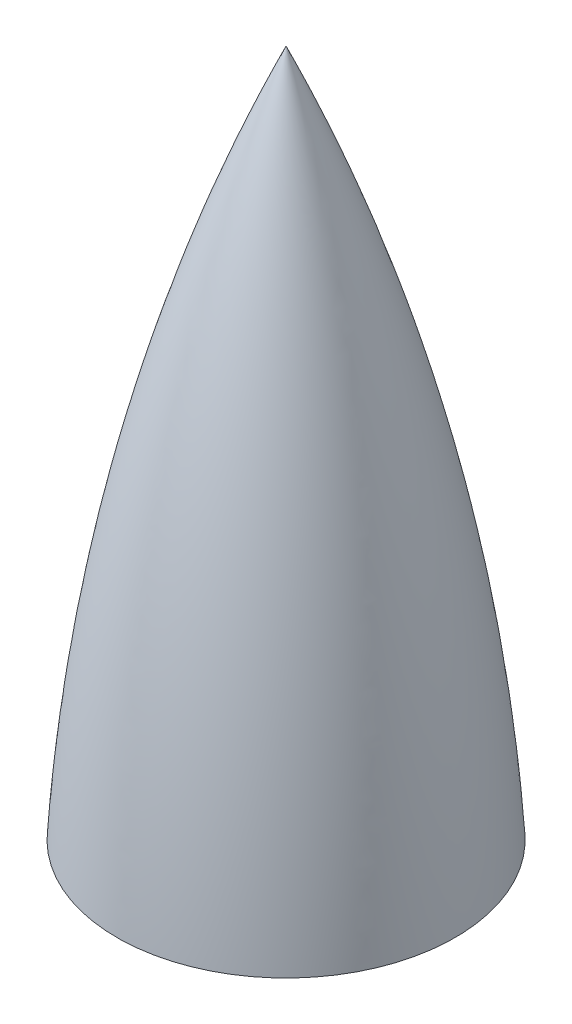
from build123d import *


with BuildPart() as part:
    # Sketch2 → Revolve1 (revolve)
    with BuildSketch(Plane.XY):
        with BuildLine():
            Line((-93.6625, 0), (-88.9, 0))
            ThreePointArc((-88.9, 0), (-59.590343886, 191.54048673), (0, 375.92))
            Line((0, 375.92), (0, 381))
            ThreePointArc((0, 381), (-64.060899281, 194.735622115), (-93.6625, 0))
        make_face()
    revolve(axis=Axis((0, 381, 0), (0, -1, 0)))


solid = part.part
